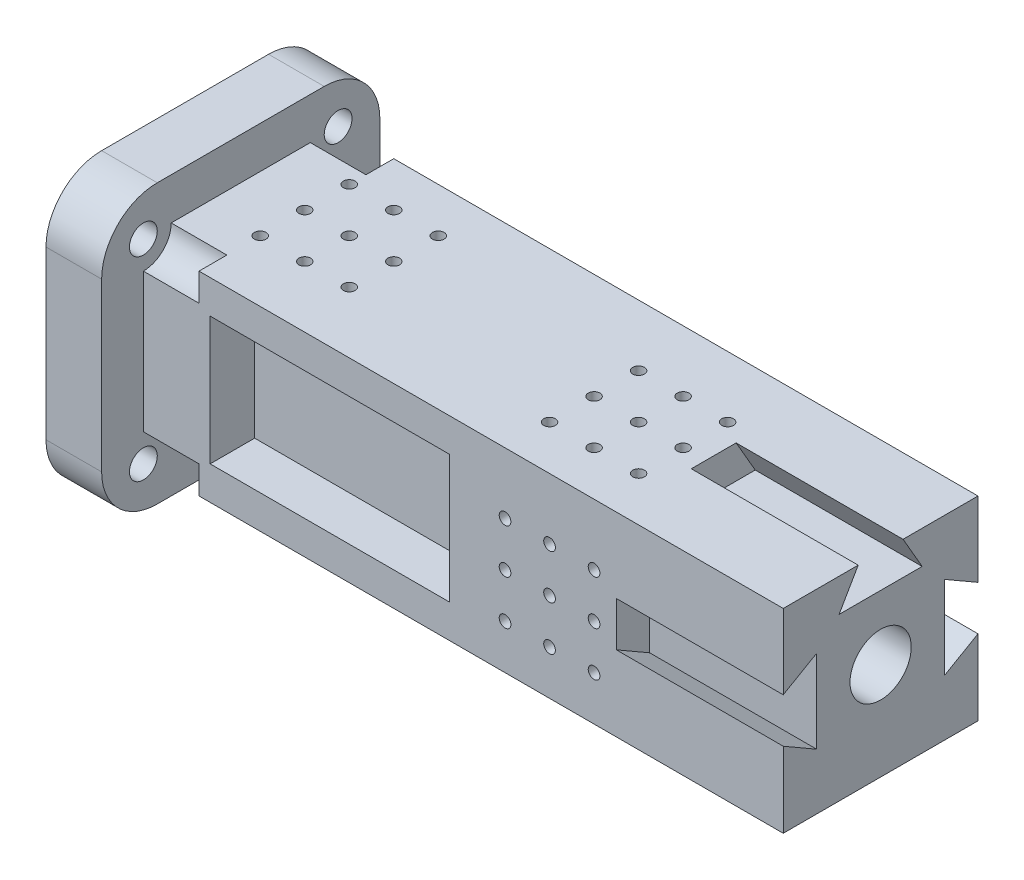
from build123d import *

# Parameters (mm, degrees)
SKETCH1_W           = 35
SKETCH1_H           = 35
SKETCH1_R           = 5.5
BOSS_EXTRUDE1_DEPTH = 115
CUT_EXTRUDE2_DEPTH  = 30
SKETCH3_W           = 50
SKETCH3_H           = 50
SKETCH3_R           = 5.5
BOSS_EXTRUDE2_DEPTH = 10
SKETCH4_R           = 2.5
CUT_EXTRUDE3_DEPTH  = 15
SKETCH6_R           = 1.05
CUT_EXTRUDE4_DEPTH  = 5
SKETCH7_R           = 1.05
CUT_EXTRUDE5_DEPTH  = 5
SKETCH8_R           = 1.05
CUT_EXTRUDE6_DEPTH  = 5
SKETCH9_R           = 1.05
CUT_EXTRUDE7_DEPTH  = 5
SKETCH11_R          = 1.05
CUT_EXTRUDE8_DEPTH  = 5
SKETCH12_W          = 43
SKETCH12_H          = 23
CUT_EXTRUDE9_DEPTH  = 8
SKETCH13_W          = 40
SKETCH13_H          = 23
CUT_EXTRUDE10_DEPTH = 8
FILLET1_R           = 10
SKETCH14_R          = 5
CUT_EXTRUDE11_DEPTH = 10
CUT_EXTRUDE12_REACH = 44.5
SKETCH15_R          = 2.5


with BuildPart() as part:
    # Sketch1 → Boss-Extrude1 (new body)
    with BuildSketch(Plane(origin=(0, 0, 0), x_dir=(0, 0, -1), z_dir=(1, 0, 0))):
        with Locations((17.5, 17.5)):
            Rectangle(SKETCH1_W, SKETCH1_H)
        with Locations((17.5, 17.5)):
            Circle(SKETCH1_R, mode=Mode.SUBTRACT)
    extrude(amount=BOSS_EXTRUDE1_DEPTH)

    # Sketch2 → Cut-Extrude2 (cut)
    with BuildSketch(Plane(origin=(115, 0, 0), x_dir=(0, 0, -1), z_dir=(1, 0, 0))):
        Polygon((0, 13.553396292), (6, 10.089294677), (6, 25.017497907), (0, 21.553396292), (-1, 21.553396292), (-1, 13.553396292), align=None)
        Polygon((21.5, 35.053396292), (21.5, 36.053396292), (13.5, 36.053396292), (13.5, 35.053396292), (10.035898385, 29.053396292), (24.964101615, 29.053396292), align=None)
        Polygon((35, 13.553396292), (36, 13.553396292), (36, 21.553396292), (35, 21.553396292), (29, 25.017497907), (29, 10.089294677), align=None)
    extrude(amount=-CUT_EXTRUDE2_DEPTH, mode=Mode.SUBTRACT)

    # Sketch3 → Boss-Extrude2 (add)
    with BuildSketch(Plane.ZY):
        with Locations((-17.5, 17.5)):
            Rectangle(SKETCH3_W, SKETCH3_H)
        with Locations((-17.5, 17.5)):
            Circle(SKETCH3_R, mode=Mode.SUBTRACT)
    extrude(amount=BOSS_EXTRUDE2_DEPTH)

    # Sketch4 → Cut-Extrude3 (cut)
    with BuildSketch(Plane.ZY.offset(10)):
        with Locations((-35, 35)):
            Circle(SKETCH4_R)
        with Locations((-35, 0)):
            Circle(SKETCH4_R)
        Circle(SKETCH4_R)
        with Locations((0, 35)):
            Circle(SKETCH4_R)
    extrude(amount=-CUT_EXTRUDE3_DEPTH, mode=Mode.SUBTRACT)

    # Sketch6 → Cut-Extrude4 (cut)
    with BuildSketch(Plane(origin=(0, 0, 0), x_dir=(-1, 0, 0), z_dir=(0, 0, 1))):
        with Locations((-65, -8)):
            Circle(SKETCH6_R)
        with Locations((-73, -8)):
            Circle(SKETCH6_R)
        with Locations((-81, -8)):
            Circle(SKETCH6_R)
        with Locations((-73, -16)):
            Circle(SKETCH6_R)
        with Locations((-81, -16)):
            Circle(SKETCH6_R)
        with Locations((-73, -24)):
            Circle(SKETCH6_R)
        with Locations((-81, -24)):
            Circle(SKETCH6_R)
        with Locations((-65, -16)):
            Circle(SKETCH6_R)
        with Locations((-65, -24)):
            Circle(SKETCH6_R)
    extrude(amount=-CUT_EXTRUDE4_DEPTH, mode=Mode.SUBTRACT)

    # Sketch7 → Cut-Extrude5 (cut)
    with BuildSketch(Plane(origin=(0, 35, 0), x_dir=(-1, 0, 0), z_dir=(0, 1, 0))):
        with Locations((-65, -8)):
            Circle(SKETCH7_R)
        with Locations((-73, -8)):
            Circle(SKETCH7_R)
        with Locations((-81, -8)):
            Circle(SKETCH7_R)
        with Locations((-73, -16)):
            Circle(SKETCH7_R)
        with Locations((-81, -16)):
            Circle(SKETCH7_R)
        with Locations((-73, -24)):
            Circle(SKETCH7_R)
        with Locations((-81, -24)):
            Circle(SKETCH7_R)
        with Locations((-65, -16)):
            Circle(SKETCH7_R)
        with Locations((-65, -24)):
            Circle(SKETCH7_R)
    extrude(amount=-CUT_EXTRUDE5_DEPTH, mode=Mode.SUBTRACT)

    # Sketch8 → Cut-Extrude6 (cut)
    with BuildSketch(Plane(origin=(0, 0, -35), x_dir=(1, 0, 0), z_dir=(0, 0, -1))):
        with Locations((81, -11)):
            Circle(SKETCH8_R)
        with Locations((73, -11)):
            Circle(SKETCH8_R)
        with Locations((65, -11)):
            Circle(SKETCH8_R)
        with Locations((73, -19)):
            Circle(SKETCH8_R)
        with Locations((65, -19)):
            Circle(SKETCH8_R)
        with Locations((73, -27)):
            Circle(SKETCH8_R)
        with Locations((65, -27)):
            Circle(SKETCH8_R)
        with Locations((81, -19)):
            Circle(SKETCH8_R)
        with Locations((81, -27)):
            Circle(SKETCH8_R)
    extrude(amount=-CUT_EXTRUDE6_DEPTH, mode=Mode.SUBTRACT)

    # Sketch9 → Cut-Extrude7 (cut)
    with BuildSketch(Plane.XZ):
        with Locations((56, -11)):
            Circle(SKETCH9_R)
        with Locations((48, -11)):
            Circle(SKETCH9_R)
        with Locations((40, -11)):
            Circle(SKETCH9_R)
        with Locations((48, -19)):
            Circle(SKETCH9_R)
        with Locations((40, -19)):
            Circle(SKETCH9_R)
        with Locations((48, -27)):
            Circle(SKETCH9_R)
        with Locations((40, -27)):
            Circle(SKETCH9_R)
        with Locations((56, -19)):
            Circle(SKETCH9_R)
        with Locations((56, -27)):
            Circle(SKETCH9_R)
    extrude(amount=-CUT_EXTRUDE7_DEPTH, mode=Mode.SUBTRACT)

    # Sketch11 → Cut-Extrude8 (cut)
    with BuildSketch(Plane(origin=(0, 35, 0), x_dir=(-1, 0, 0), z_dir=(0, 1, 0))):
        with Locations((-10, -11)):
            Circle(SKETCH11_R)
        with Locations((-18, -11)):
            Circle(SKETCH11_R)
        with Locations((-26, -11)):
            Circle(SKETCH11_R)
        with Locations((-18, -19)):
            Circle(SKETCH11_R)
        with Locations((-26, -19)):
            Circle(SKETCH11_R)
        with Locations((-18, -27)):
            Circle(SKETCH11_R)
        with Locations((-26, -27)):
            Circle(SKETCH11_R)
        with Locations((-10, -19)):
            Circle(SKETCH11_R)
        with Locations((-10, -27)):
            Circle(SKETCH11_R)
    extrude(amount=-CUT_EXTRUDE8_DEPTH, mode=Mode.SUBTRACT)

    # Sketch12 → Cut-Extrude9 (cut)
    with BuildSketch(Plane.XY):
        with Locations((33.5, 17.5)):
            Rectangle(SKETCH12_W, SKETCH12_H)
    extrude(amount=-CUT_EXTRUDE9_DEPTH, mode=Mode.SUBTRACT)

    # Sketch13 → Cut-Extrude10 (cut)
    with BuildSketch(Plane(origin=(0, 0, -35), x_dir=(-1, 0, 0), z_dir=(0, 0, -1))):
        with Locations((-35, 17.5)):
            Rectangle(SKETCH13_W, SKETCH13_H)
    extrude(amount=-CUT_EXTRUDE10_DEPTH, mode=Mode.SUBTRACT)

    # Fillet1
    fillet1_edges = [part.edges().sort_by_distance(p)[0] for p in [
        (-5, -7.5, 7.5),
        (-5, 42.5, 7.5),
        (-5, 42.5, -42.5),
        (-5, -7.5, -42.5),
    ]]
    fillet(fillet1_edges, radius=FILLET1_R)

    # Sketch14 → Cut-Extrude11 (cut)
    with BuildSketch(Plane(origin=(0, 0, 0), x_dir=(0, 0, -1), z_dir=(1, 0, 0))):
        Circle(SKETCH14_R)
        with Locations((35, 0)):
            Circle(SKETCH14_R)
        with Locations((35, 35)):
            Circle(SKETCH14_R)
        with Locations((0, 35)):
            Circle(SKETCH14_R)
    extrude(amount=CUT_EXTRUDE11_DEPTH, mode=Mode.SUBTRACT)

    # Sketch15 → Cut-Extrude12 (cut, up to next)
    with BuildSketch(Plane.XZ, mode=Mode.PRIVATE) as cut_extrude12_sk1:
        with Locations((100, -17.5)):
            Circle(SKETCH15_R)
    cut_extrude12_tool1 = extrude(cut_extrude12_sk1.sketch, amount=-CUT_EXTRUDE12_REACH, mode=Mode.PRIVATE) & part.part
    add(cut_extrude12_tool1.solids().sort_by_distance((100, 0, -17.5))[0], mode=Mode.SUBTRACT)


solid = part.part
